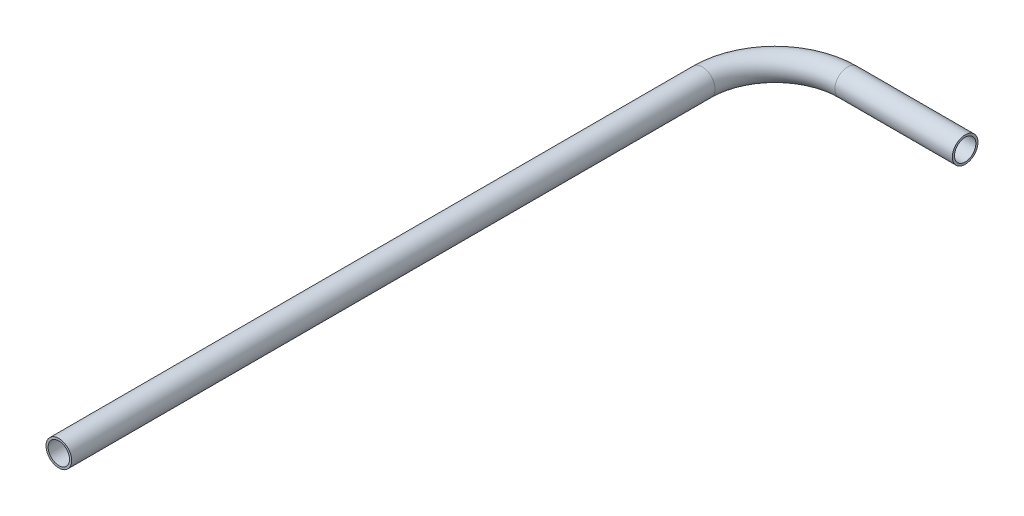
from build123d import *

# Parameters (mm, degrees)
SKETCH2_R   = 3
SKETCH2_R_2 = 2.5


with BuildPart() as part:
    # Sweep1: sweep along a path in Sketch1
    with BuildLine(Plane(origin=(0, 0, 0), x_dir=(1, 0, 0), z_dir=(0, 1, 0))) as sweep1_path:
        Line((0, 0), (0, 150.5))
        ThreePointArc((0, 150.5), (4.97918472, 162.52081528), (17, 167.5))
        Line((17, 167.5), (44.5, 167.5))
    # Sketch2 → Sweep1 (sweep)
    with BuildSketch(Plane.XY):
        Circle(SKETCH2_R)
        Circle(SKETCH2_R_2, mode=Mode.SUBTRACT)
    sweep(path=sweep1_path.line)


solid = part.part
